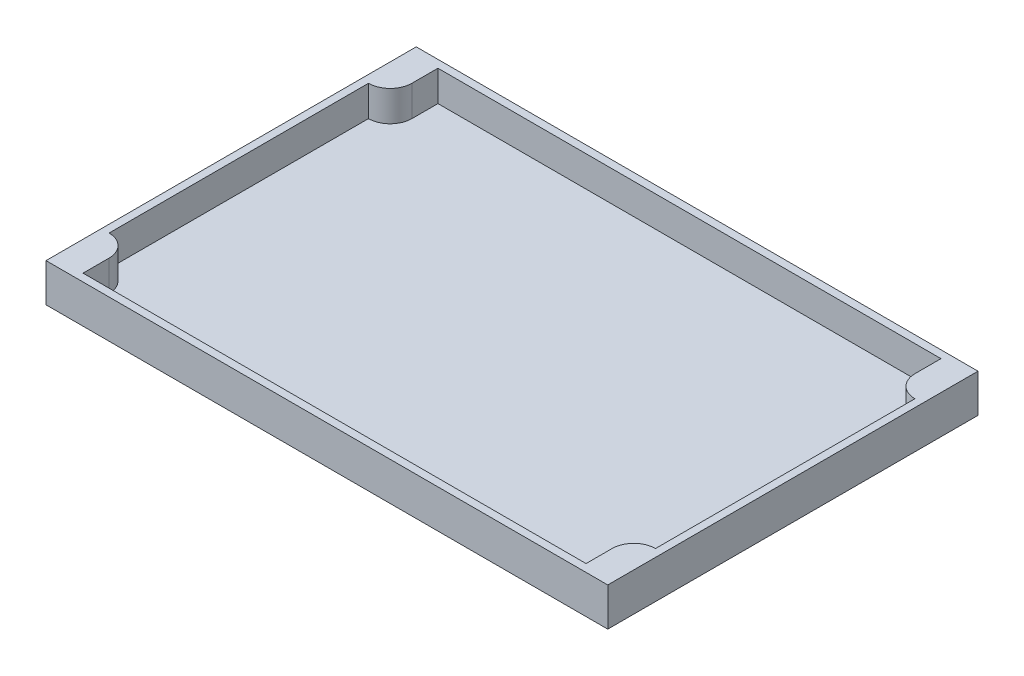
from build123d import *

# Parameters (mm, degrees)
SKETCH1_W           = 220
SKETCH1_H           = 145
BOSS_EXTRUDE1_DEPTH = 3
SKETCH2_W           = 220
SKETCH2_H           = 145
BOSS_EXTRUDE2_DEPTH = 12


with BuildPart() as part:
    # Sketch1 → Boss-Extrude1 (new body)
    with BuildSketch(Plane(origin=(0, 0, 0), x_dir=(1, 0, 0), z_dir=(0, 1, 0))):
        with Locations((110, 72.5)):
            Rectangle(SKETCH1_W, SKETCH1_H)
    extrude(amount=BOSS_EXTRUDE1_DEPTH)

    # Sketch2 → Boss-Extrude2 (add)
    with BuildSketch(Plane(origin=(0, 3, 0), x_dir=(1, 0, 0), z_dir=(0, 1, 0))):
        with Locations((110, 72.5)):
            Rectangle(SKETCH2_W, SKETCH2_H)
        with BuildLine():
            Line((3, 123.3), (3, 21.7))
            ThreePointArc((3, 21.7), (9.01040764, 19.21040764), (11.5, 13.2))
            Line((11.5, 13.2), (11.5, 3))
            Line((11.5, 3), (208.5, 3))
            Line((208.5, 3), (208.5, 13.2))
            ThreePointArc((208.5, 13.2), (210.98959236, 19.21040764), (217, 21.7))
            Line((217, 21.7), (217, 123.3))
            ThreePointArc((217, 123.3), (210.98959236, 125.78959236), (208.5, 131.8))
            Line((208.5, 131.8), (208.5, 142))
            Line((208.5, 142), (11.5, 142))
            Line((11.5, 142), (11.5, 131.8))
            ThreePointArc((11.5, 131.8), (9.01040764, 125.78959236), (3, 123.3))
        make_face(mode=Mode.SUBTRACT)
    extrude(amount=BOSS_EXTRUDE2_DEPTH)


solid = part.part
